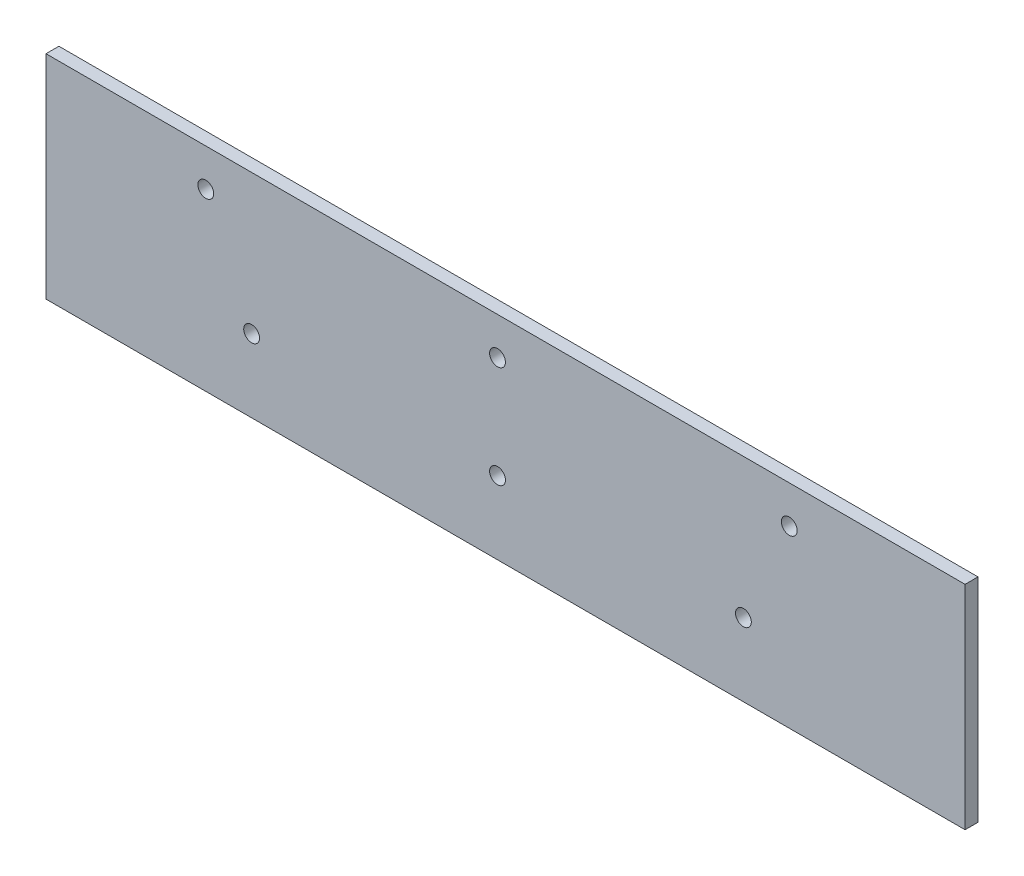
from build123d import *

# Parameters (mm, degrees)
SKETCH1_W             = 220.5325
SKETCH1_H             = 51
BOSS_EXTRUDE1_DEPTH   = 3.1
F_6_CLEARANCE_HOLE1_D = 3.7973


with BuildPart() as part:
    # Sketch1 → Boss-Extrude1 (new body)
    with BuildSketch(Plane.XY):
        Rectangle(SKETCH1_W, SKETCH1_H)
    extrude(amount=BOSS_EXTRUDE1_DEPTH)

    # #6 Clearance Hole1 (through all)
    with Locations(Plane.XY.offset(3.1)):
        with Locations((-71.925, 16.5), (-60.925, -8), (-1.925, -8), (-1.925, 16.5), (68.075, 16.5), (57.075, -8)):
            Hole(F_6_CLEARANCE_HOLE1_D / 2)


solid = part.part
